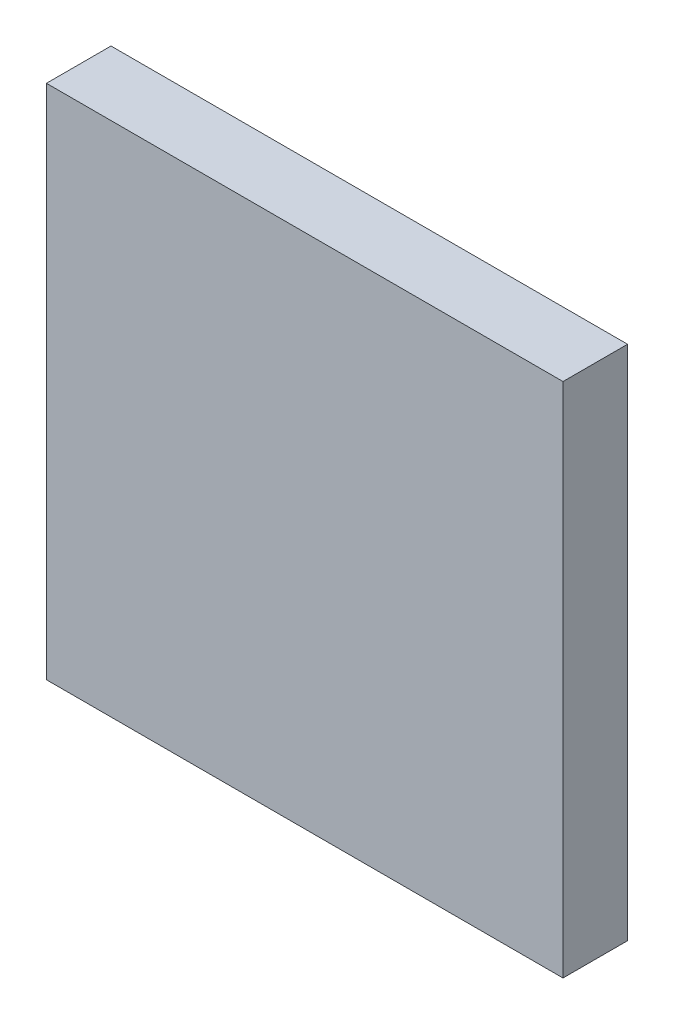
from build123d import *

# Parameters (mm, degrees)
SKETCH1_W           = 80
SKETCH1_H           = 80
BOSS_EXTRUDE1_DEPTH = 10


with BuildPart() as part:
    # Sketch1 → Boss-Extrude1 (new body)
    with BuildSketch(Plane.XY):
        Rectangle(SKETCH1_W, SKETCH1_H)
    extrude(amount=BOSS_EXTRUDE1_DEPTH)


solid = part.part
